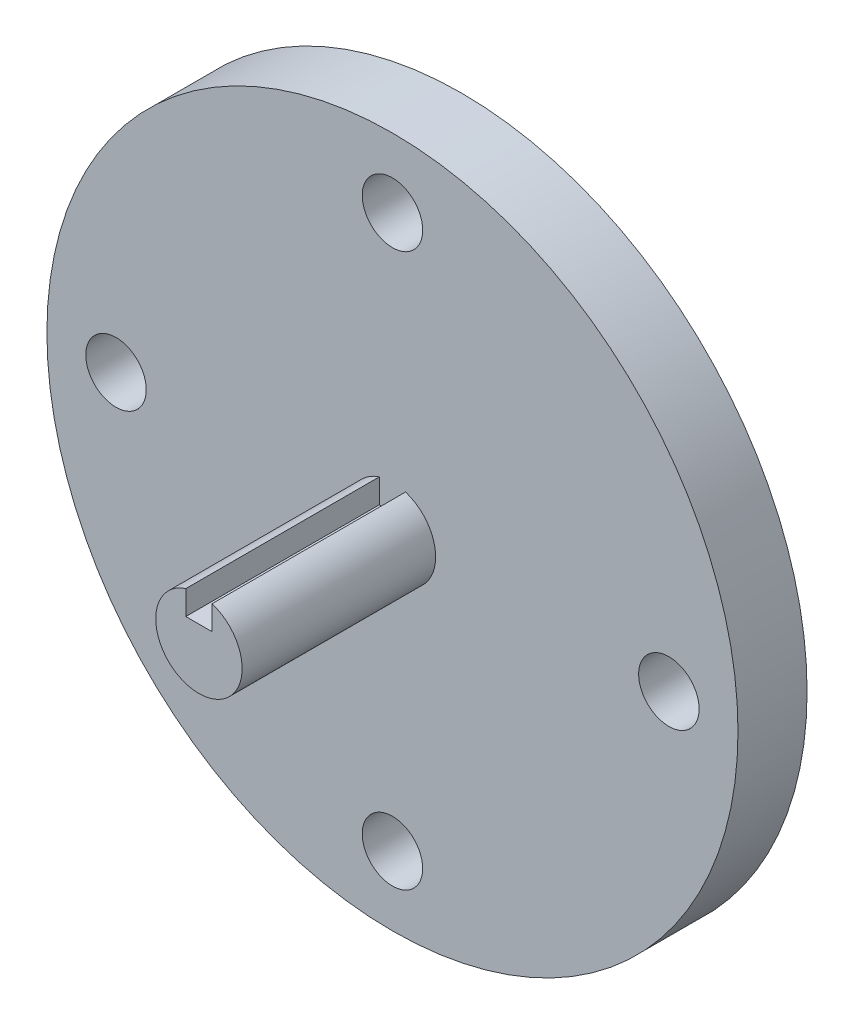
from build123d import *

# Parameters (mm, degrees)
SKETCH1_R           = 63.5
SKETCH1_R_2         = 5.55625
BOSS_EXTRUDE1_DEPTH = 12.7
BOSS_EXTRUDE5_DEPTH = 48.26


with BuildPart() as part:
    # Sketch1 → Boss-Extrude1 (new body)
    with BuildSketch(Plane.XY):
        Circle(SKETCH1_R)
        with Locations((-50.8, 0)):
            Circle(SKETCH1_R_2, mode=Mode.SUBTRACT)
        with Locations((0, 50.8)):
            Circle(SKETCH1_R_2, mode=Mode.SUBTRACT)
        with Locations((50.8, 0)):
            Circle(SKETCH1_R_2, mode=Mode.SUBTRACT)
        with Locations((0, -50.8)):
            Circle(SKETCH1_R_2, mode=Mode.SUBTRACT)
    extrude(amount=BOSS_EXTRUDE1_DEPTH)

    # Sketch2 → Boss-Extrude5 (add)
    with BuildSketch(Plane(origin=(0, 0, 0), x_dir=(-1, 0, 0), z_dir=(0, 0, -1))):
        with BuildLine():
            Line((-2.413, 7.561834252), (-2.413, 3.1115))
            Line((-2.413, 3.1115), (2.413, 3.1115))
            Line((2.413, 3.1115), (2.413, 7.561834252))
            ThreePointArc((2.413, 7.561834252), (0, -7.9375), (-2.413, 7.561834252))
        make_face()
    extrude(amount=-BOSS_EXTRUDE5_DEPTH)


solid = part.part
